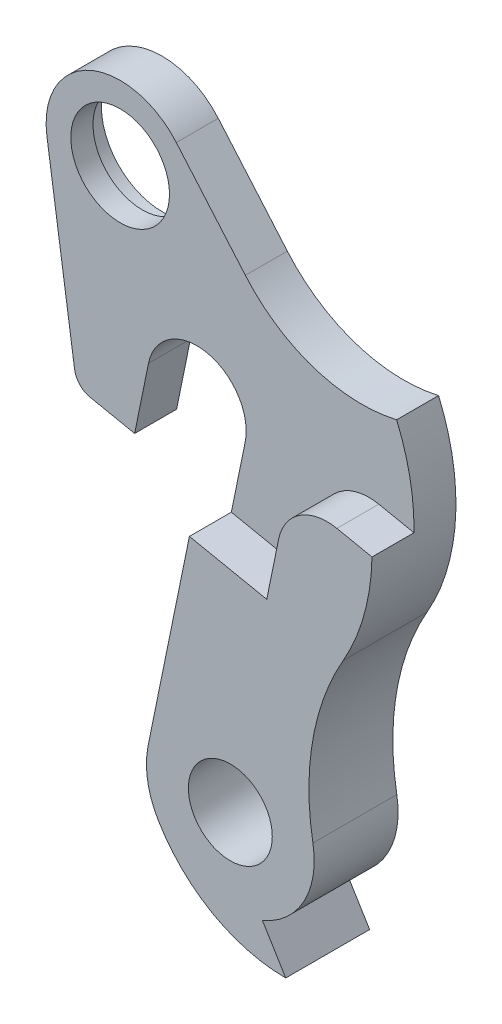
from build123d import *

# Parameters (mm, degrees)
EXTRUSION12_DEPTH             = 4.25
ENL_V_MAT_EXTRU_13_DEPTH      = 5.25
ESQUISSE35_R                  = 5
ESQUISSE35_R_2                = 4.25
ENL_V_MAT_EXTRU_14_DEPTH      = 5.25
ENL_V_MAT_EXTRU_14_DEPTH_BACK = 5.25
ESQUISSE36_R                  = 6.15
ENL_V_MAT_EXTRU_15_DEPTH      = 2


with BuildPart() as part:
    # Esquisse33 → Extrusion12 (new body, symmetric)
    with BuildSketch(Plane.XY):
        with BuildLine():
            Line((10.891822315, -37.854750679), (13.257957999, -41.725))
            ThreePointArc((13.257957999, -41.725), (5.786859841, -39.732024729), (0.301056866, -34.282692308))
            ThreePointArc((0.301056866, -34.282692308), (-0.743831674, -31.380582548), (-0.684284829, -28.296674752))
            Line((-0.684284829, -28.296674752), (4.898579806, -1.001956028))
            ThreePointArc((4.898579806, -1.001956028), (1.001956028, 4.898579806), (-4.898579806, 1.001956028))
            Line((-4.898579806, 1.001956028), (-6.301318246, -5.8560557))
            Line((-6.301318246, -5.8560557), (-10.805878352, -4.934692503))
            ThreePointArc((-10.805878352, -4.934692503), (-11.858094208, -4.349595341), (-12.383780945, -3.266474687))
            Line((-12.383780945, -3.266474687), (-15.191076253, 15.807989781))
            ThreePointArc((-15.191076253, 15.807989781), (-10.881496713, 23.724620088), (-2.079236513, 21.784072078))
            Line((-2.079236513, 21.784072078), (4.917258536, 13.630466886))
            ThreePointArc((4.917258536, 13.630466886), (11.878383999, 8.981113225), (20.241537521, 8.618593782))
            ThreePointArc((20.241537521, 8.618593782), (21.960728113, -1.313933303), (19.069494762, -10.970613909))
            ThreePointArc((19.069494762, -10.970613909), (15.992864342, -19.46838522), (16.010964353, -28.505942654))
            ThreePointArc((16.010964353, -28.505942654), (15.098768048, -34.082402323), (10.891822315, -37.854750679))
        make_face()
    extrude(amount=EXTRUSION12_DEPTH, both=True)

    # Esquisse34 → Enlèv. mat.-Extru.13 (cut, through all)
    with BuildSketch(Plane.XY):
        with BuildLine():
            Line((4.898579806, -1.001956028), (3.495841367, -7.859967757))
            Line((3.495841367, -7.859967757), (11.333569057, -9.463097402))
            Line((11.333569057, -9.463097402), (12.53591629, -3.584801635))
            ThreePointArc((12.53591629, -3.584801635), (14.679166999, -0.414448762), (18.436452125, 0.311822143))
            Line((18.436452125, 0.311822143), (21.996061624, -0.416260758))
            ThreePointArc((21.996061624, -0.416260758), (21.596547051, 4.193942712), (20.241537521, 8.618593782))
            ThreePointArc((20.241537521, 8.618593782), (11.878383999, 8.981113225), (4.917258536, 13.630466886))
            Line((4.917258536, 13.630466886), (-2.079236513, 21.784072078))
            ThreePointArc((-2.079236513, 21.784072078), (-10.881496713, 23.724620088), (-15.191076253, 15.807989781))
            Line((-15.191076253, 15.807989781), (-12.383780945, -3.266474687))
            ThreePointArc((-12.383780945, -3.266474687), (-11.858094208, -4.349595341), (-10.805878352, -4.934692503))
            Line((-10.805878352, -4.934692503), (-6.301318246, -5.8560557))
            Line((-6.301318246, -5.8560557), (-4.898579806, 1.001956028))
            ThreePointArc((-4.898579806, 1.001956028), (1.001956028, 4.898579806), (4.898579806, -1.001956028))
        make_face()
    extrude(amount=ENL_V_MAT_EXTRU_13_DEPTH, mode=Mode.SUBTRACT)

    # Esquisse35 → Enlèv. mat.-Extru.14 (cut, two sides)
    with BuildSketch(Plane.XY) as enl_v_mat_extru_14_sk:
        with Locations((-7.771007489, 16.900042681)):
            Circle(ESQUISSE35_R)
        with Locations((7.643300841, -30)):
            Circle(ESQUISSE35_R_2)
    extrude(amount=ENL_V_MAT_EXTRU_14_DEPTH, mode=Mode.SUBTRACT)
    extrude(enl_v_mat_extru_14_sk.sketch, amount=-ENL_V_MAT_EXTRU_14_DEPTH_BACK, mode=Mode.SUBTRACT)

    # Esquisse36 → Enlèv. mat.-Extru.15 (cut)
    with BuildSketch(Plane(origin=(0, 0, -4.25), x_dir=(-1, 0, 0), z_dir=(0, 0, -1))):
        with Locations((7.771007489, 16.900042681)):
            Circle(ESQUISSE36_R)
    extrude(amount=-ENL_V_MAT_EXTRU_15_DEPTH, mode=Mode.SUBTRACT)


solid = part.part
